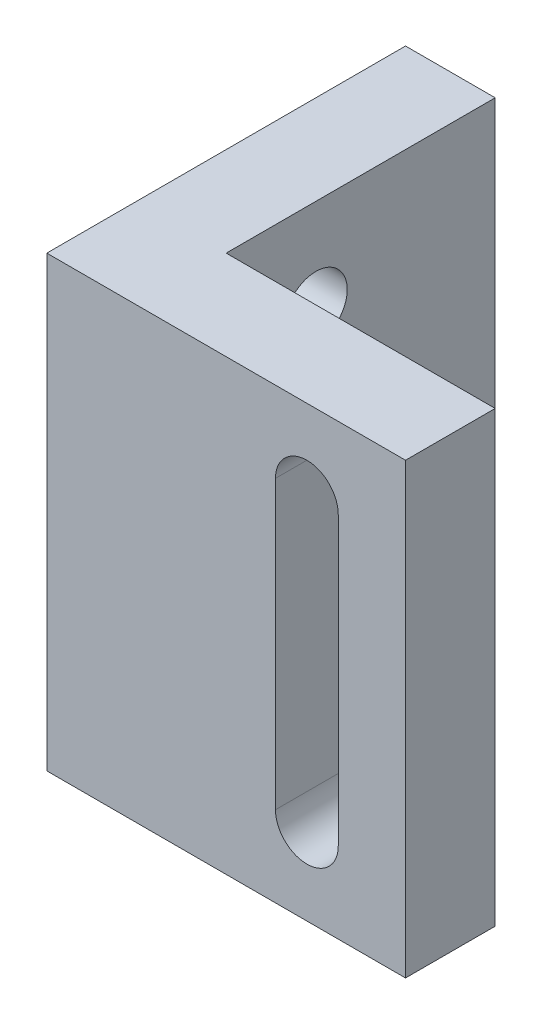
from build123d import *

# Parameters (mm, degrees)
BOSS_EXTRUDE1_DEPTH = 25
CUT_EXTRUDE1_DEPTH  = 5
SKETCH3_R           = 1.75
CUT_EXTRUDE2_DEPTH  = 5


with BuildPart() as part:
    # Sketch1 → Boss-Extrude1 (new body)
    with BuildSketch(Plane(origin=(0, 0, 0), x_dir=(1, 0, 0), z_dir=(0, 1, 0))):
        Polygon((-5, 15), (-5, -5), (15, -5), (15, 0), (0, 0), (0, 15), align=None)
    extrude(amount=BOSS_EXTRUDE1_DEPTH)

    # Sketch2 → Cut-Extrude1 (cut)
    with BuildSketch(Plane(origin=(0, 0, 0), x_dir=(-1, 0, 0), z_dir=(0, 0, -1))):
        with BuildLine():
            Line((-7.75, 20.5), (-7.75, 4.5))
            ThreePointArc((-7.75, 4.5), (-9.5, 2.75), (-11.25, 4.5))
            Line((-11.25, 4.5), (-11.25, 20.5))
            ThreePointArc((-11.25, 20.5), (-9.5, 22.25), (-7.75, 20.5))
        make_face()
    extrude(amount=-CUT_EXTRUDE1_DEPTH, mode=Mode.SUBTRACT)

    # Sketch3 → Cut-Extrude2 (cut)
    with BuildSketch(Plane.ZY.offset(5)):
        with Locations((-5, 5.134)):
            Circle(SKETCH3_R)
        with Locations((-5, 19.866)):
            Circle(SKETCH3_R)
    extrude(amount=-CUT_EXTRUDE2_DEPTH, mode=Mode.SUBTRACT)


solid = part.part
